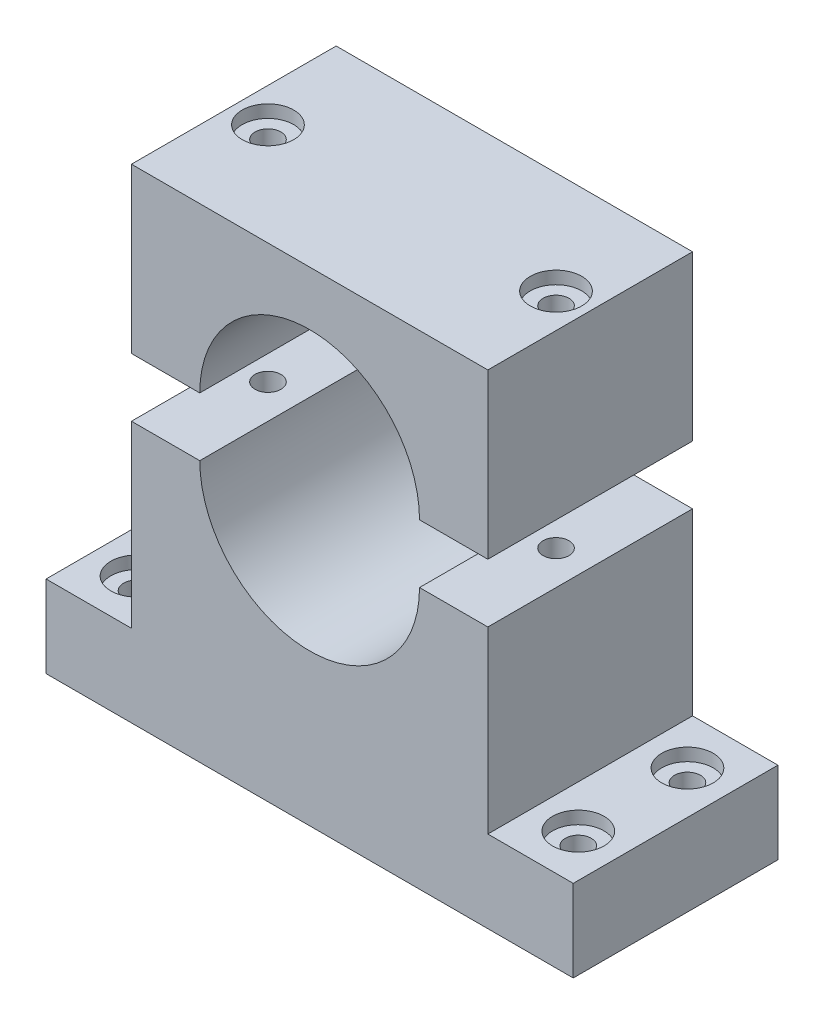
from build123d import *

# Parameters (mm, degrees)
BOSS_EXTRUDE1_DEPTH                           = 30
BOSS_EXTRUDE1_2_DEPTH                         = 30
CBORE_FOR_6_BUTTON_HEAD_CAP_SCREW1_AT_2_COUNT = 2
CBORE_FOR_6_BUTTON_HEAD_CAP_SCREW1_AT_2_PITCH = 42.21750368
CBORE_FOR_6_BUTTON_HEAD_CAP_SCREW2_AT_2_COUNT = 2
CBORE_FOR_6_BUTTON_HEAD_CAP_SCREW2_AT_2_PITCH = 64.744630149
CBORE_FOR_6_BUTTON_HEAD_CAP_SCREW2_AT_3_COUNT = 2
CBORE_FOR_6_BUTTON_HEAD_CAP_SCREW2_AT_3_PITCH = 66.692331892
CBORE_FOR_6_BUTTON_HEAD_CAP_SCREW2_AT_4_COUNT = 2
CBORE_FOR_6_BUTTON_HEAD_CAP_SCREW2_AT_4_PITCH = 16


with BuildPart() as part:
    # Sketch1 → Boss-Extrude1 (new body)
    with BuildSketch(Plane.XY):
        with BuildLine():
            Line((0, 0), (-10.012056209, 0))
            Line((-10.012056209, 0), (-10.012056209, -26.281647548))
            Line((-10.012056209, -26.281647548), (-22.527126469, -26.281647548))
            Line((-22.527126469, -26.281647548), (-22.527126469, -38.296114998))
            Line((-22.527126469, -38.296114998), (54.73257394, -38.296114998))
            Line((54.73257394, -38.296114998), (54.73257394, -26.281647548))
            Line((54.73257394, -26.281647548), (42.21750368, -26.281647548))
            Line((42.21750368, -26.281647548), (42.21750368, 0))
            Line((42.21750368, 0), (32.205447471, 0))
            ThreePointArc((32.205447471, 0), (16.102723736, -16.102723736), (0, 0))
        make_face()
    extrude(amount=BOSS_EXTRUDE1_DEPTH)


with BuildPart() as body_2:
    # Sketch1 → Boss-Extrude1 2 (new body)
    with BuildSketch(Plane.XY):
        with BuildLine():
            Line((0, 8.593681579), (-10.012056209, 8.593681579))
            Line((-10.012056209, 8.593681579), (-10.012056209, 32.62261648))
            Line((-10.012056209, 32.62261648), (42.21750368, 32.62261648))
            Line((42.21750368, 32.62261648), (42.21750368, 8.593681579))
            Line((42.21750368, 8.593681579), (32.205447471, 8.593681579))
            ThreePointArc((32.205447471, 8.593681579), (16.102723736, 24.696405315), (0, 8.593681579))
        make_face()
    extrude(amount=BOSS_EXTRUDE1_2_DEPTH)


with BuildPart() as cbore_for_6_button_head_cap_screw1_tool:
    # Sketch3 → CBORE for #6 Button Head Cap Screw1 (revolve)
    with BuildSketch(Plane(origin=(37.211475575, 32.62261648, 15), x_dir=(0, 0, 1), z_dir=(1, 0, 0))):
        Polygon((0, 0), (0, 70.918731478), (1.89865, 70.918731478), (1.89865, 1.8542), (3.77063, 1.8542), (3.77063, 0), align=None)
    cbore_for_6_button_head_cap_screw1 = revolve(axis=Axis((37.211475575, 38.97261648, 15), (0, -1, 0)))


with BuildPart() as part_1:
    add(part.part)

    # CBORE for #6 Button Head Cap Screw1: cut by cbore_for_6_button_head_cap_screw1_tool
    add(cbore_for_6_button_head_cap_screw1_tool.part, mode=Mode.SUBTRACT)


with BuildPart() as body_2_1:
    add(body_2.part)

    # CBORE for #6 Button Head Cap Screw1: cut by cbore_for_6_button_head_cap_screw1_tool
    add(cbore_for_6_button_head_cap_screw1_tool.part, mode=Mode.SUBTRACT)


with BuildPart() as cbore_for_6_button_head_cap_screw1_at_2_tool:
    # CBORE for #6 Button Head Cap Screw1 at 2: CBORE for #6 Button Head Cap Screw1 ×2
    with Locations(*[(-i * CBORE_FOR_6_BUTTON_HEAD_CAP_SCREW1_AT_2_PITCH, 0, 0) for i in range(1, CBORE_FOR_6_BUTTON_HEAD_CAP_SCREW1_AT_2_COUNT)]):
        add(cbore_for_6_button_head_cap_screw1)


with BuildPart() as part_2:
    add(part_1.part)

    # CBORE for #6 Button Head Cap Screw1 at 2: cut by cbore_for_6_button_head_cap_screw1_at_2_tool
    add(cbore_for_6_button_head_cap_screw1_at_2_tool.part, mode=Mode.SUBTRACT)

    # Sketch5 → CBORE for #6 Button Head Cap Screw2 (revolve, cut)
    with BuildSketch(Plane(origin=(48.47503881, -26.281647548, 7), x_dir=(0, 0, 1), z_dir=(1, 0, 0))):
        Polygon((0, 0), (0, 12.01446745), (1.89865, 12.01446745), (1.89865, 1.8542), (3.77063, 1.8542), (3.77063, 0), align=None)
    cbore_for_6_button_head_cap_screw2 = revolve(axis=Axis((48.47503881, -19.931647548, 7), (0, -1, 0)), mode=Mode.SUBTRACT)

    # CBORE for #6 Button Head Cap Screw2 at 2: CBORE for #6 Button Head Cap Screw2 ×2
    with Locations(*[(-i * CBORE_FOR_6_BUTTON_HEAD_CAP_SCREW2_AT_2_PITCH, 0, 0) for i in range(1, CBORE_FOR_6_BUTTON_HEAD_CAP_SCREW2_AT_2_COUNT)]):
        add(cbore_for_6_button_head_cap_screw2, mode=Mode.SUBTRACT)

    # CBORE for #6 Button Head Cap Screw2 at 3: CBORE for #6 Button Head Cap Screw2 ×2
    with Locations(*[Vector(-0.970795717, 0, 0.239907641) * (i * CBORE_FOR_6_BUTTON_HEAD_CAP_SCREW2_AT_3_PITCH) for i in range(1, CBORE_FOR_6_BUTTON_HEAD_CAP_SCREW2_AT_3_COUNT)]):
        add(cbore_for_6_button_head_cap_screw2, mode=Mode.SUBTRACT)

    # CBORE for #6 Button Head Cap Screw2 at 4: CBORE for #6 Button Head Cap Screw2 ×2
    with Locations(*[(0, 0, i * CBORE_FOR_6_BUTTON_HEAD_CAP_SCREW2_AT_4_PITCH) for i in range(1, CBORE_FOR_6_BUTTON_HEAD_CAP_SCREW2_AT_4_COUNT)]):
        add(cbore_for_6_button_head_cap_screw2, mode=Mode.SUBTRACT)


with BuildPart() as body_2_2:
    add(body_2_1.part)

    # CBORE for #6 Button Head Cap Screw1 at 2: cut by cbore_for_6_button_head_cap_screw1_at_2_tool
    add(cbore_for_6_button_head_cap_screw1_at_2_tool.part, mode=Mode.SUBTRACT)


solid = Compound([part_2.part, body_2_2.part])
